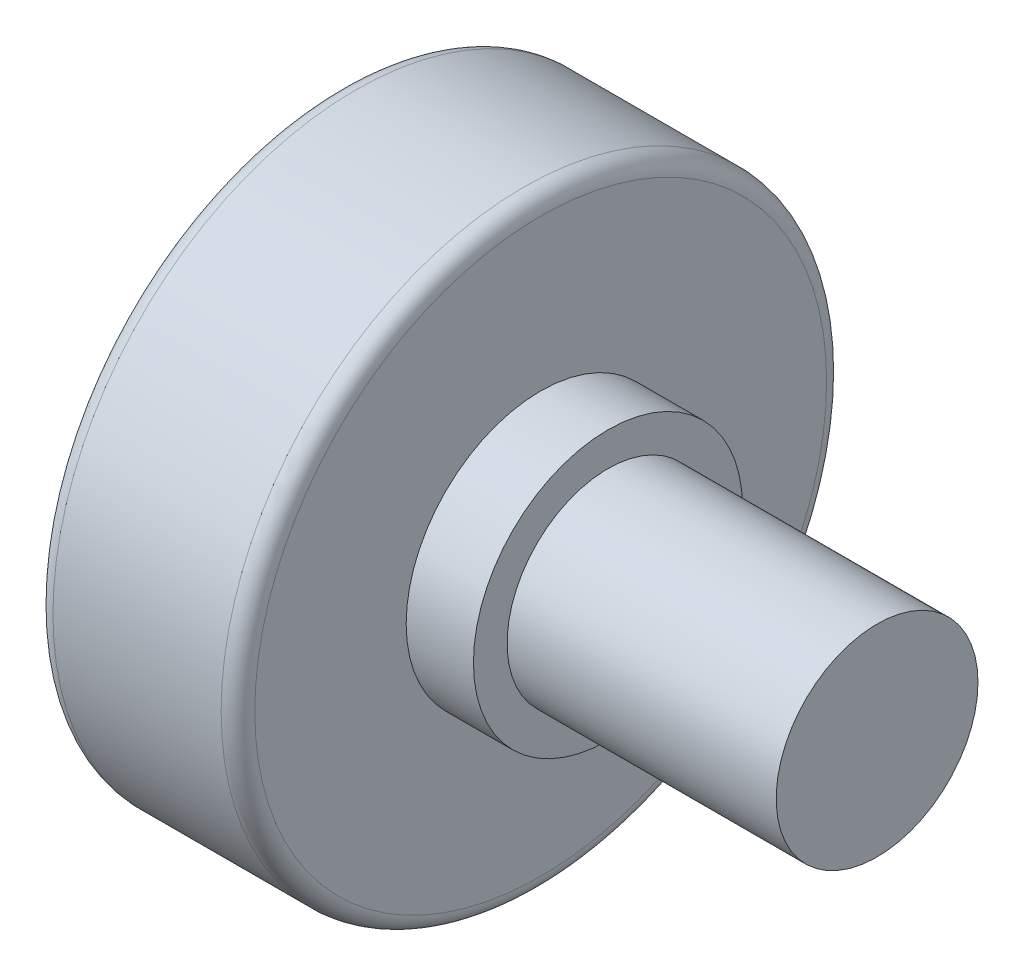
from build123d import *


with BuildPart() as part:
    # 草图1 → 旋转1 (revolve)
    with BuildSketch(Plane(origin=(0, 0, 0), x_dir=(1, 0, 0), z_dir=(0, 1, 0))):
        with BuildLine():
            Line((0, 0), (0, -8.5))
            ThreePointArc((0, -8.5), (0.146446609, -8.853553391), (0.5, -9))
            Line((0.5, -9), (5.5, -9))
            ThreePointArc((5.5, -9), (5.853553391, -8.853553391), (6, -8.5))
            Line((6, -8.5), (6, -4))
            Line((6, -4), (8, -4))
            Line((8, -4), (8, -3))
            Line((8, -3), (16, -3))
            Line((16, -3), (16, 0))
            Line((16, 0), (0, 0))
        make_face()
    revolve(axis=Axis((16, 0, 0), (-1, 0, 0)))


solid = part.part
